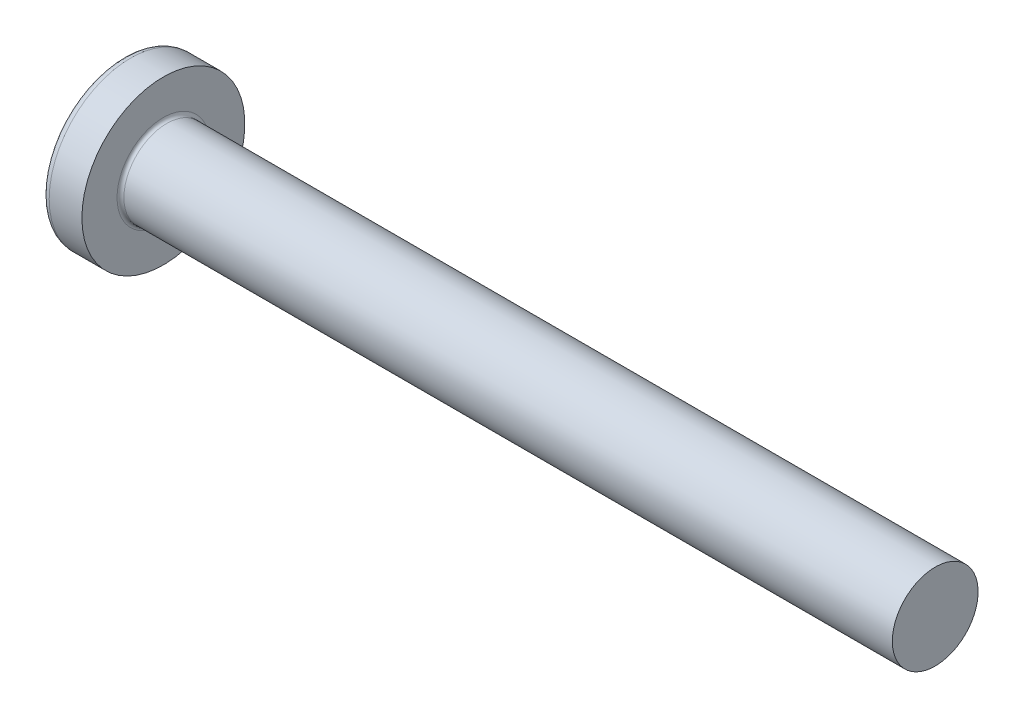
from build123d import *

# Parameters (mm, degrees)
FILLET1_R    = 0.2
SKETCH3_W    = 1.03
SKETCH3_H    = 4.7
SKETCH4_W    = 1.03
SKETCH4_H    = 1.967772882
RECPAT_COUNT = 2
RECPAT_ANGLE = 90


with BuildPart() as part:
    # BodySke → Base-Revolve (revolve)
    with BuildSketch(Plane.XY):
        with BuildLine():
            Line((3.7, 2.5), (3.7, 4.75))
            Line((3.7, 4.75), (1.79415598, 4.75))
            ThreePointArc((1.79415598, 4.75), (1.58538712, 4.698642149), (1.424271237, 4.556291391))
            ThreePointArc((1.424271237, 4.556291391), (0.364365445, 2.386856709), (0, 0))
            Line((0, 0), (48.7, 0))
            Line((48.7, 0), (48.7, 2.5))
            Line((48.7, 2.5), (3.7, 2.5))
        make_face()
    revolve(axis=Axis((-25.4, 0, 0), (1, 0, 0)))

    # Fillet1
    fillet1_edges = [part.edges().sort_by_distance(p)[0] for p in [
        (3.7, -2.5, 0),
    ]]
    fillet(fillet1_edges, radius=FILLET1_R)

    # Sketch3 → Recess section 0
    with BuildSketch(Plane(origin=(0, 0, 0), x_dir=(0, 0, -1), z_dir=(1, 0, 0))):
        Rectangle(SKETCH3_W, SKETCH3_H)
    # Sketch4 → Recess section 1
    with BuildSketch(Plane(origin=(2.74, 0, 0), x_dir=(0, 0, -1), z_dir=(1, 0, 0))):
        Rectangle(SKETCH4_W, SKETCH4_H)
    recess = loft(mode=Mode.SUBTRACT)

    # RecPat: Recess ×2 about axis
    recpat_axis = Axis((0, 0, 0), (1, 0, 0))
    for i in range(1, RECPAT_COUNT):
        add(recess.rotate(recpat_axis, i * RECPAT_ANGLE / (RECPAT_COUNT - 1)), mode=Mode.SUBTRACT)

    # RecCorSke → RecessCore (revolve, cut)
    with BuildSketch(Plane.XY):
        Polygon((0, 0), (0, 1.042599465), (2.74, 0.851), (3.016506661, 0), align=None)
    revolve(axis=Axis((-3.175, 0, 0), (1, 0, 0)), mode=Mode.SUBTRACT)


solid = part.part
